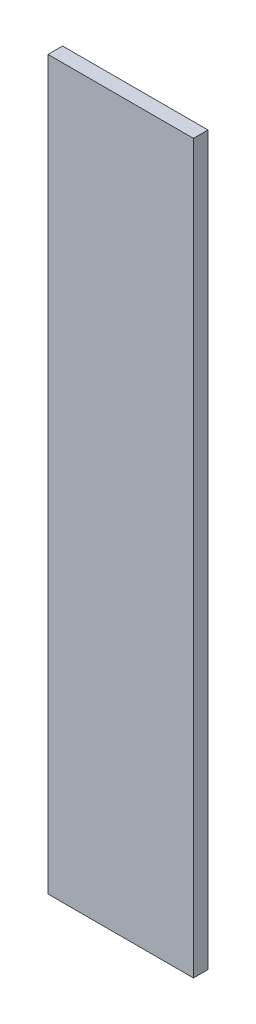
from build123d import *

# Parameters (mm, degrees)
SKETCH1_W           = 10
SKETCH1_H           = 50
BOSS_EXTRUDE1_DEPTH = 1


with BuildPart() as part:
    # Sketch1 → Boss-Extrude1 (new body)
    with BuildSketch(Plane.XY):
        Rectangle(SKETCH1_W, SKETCH1_H)
    extrude(amount=BOSS_EXTRUDE1_DEPTH)


solid = part.part
